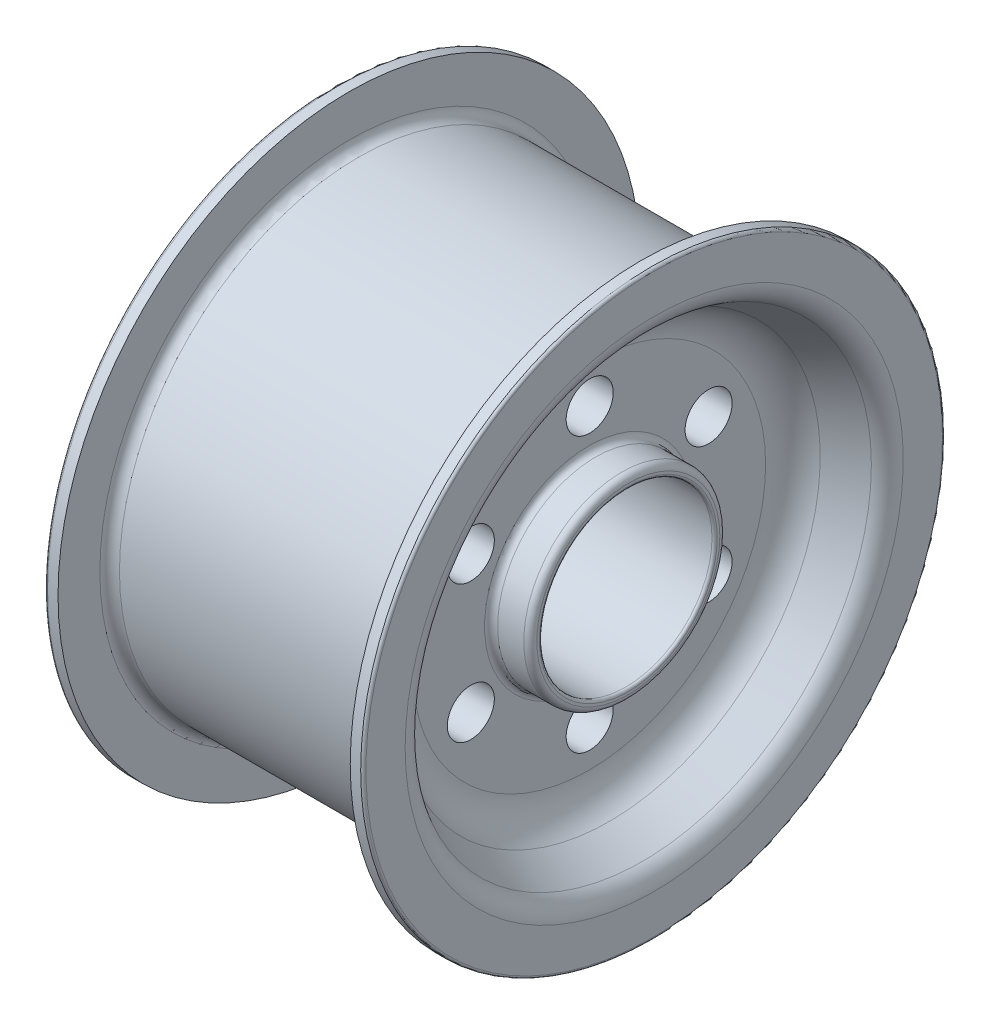
from build123d import *

# Parameters (mm, degrees)
SKETCH2_R          = 18
CUT_EXTRUDE1_DEPTH = 194.76
SKETCH3_R          = 66
CUT_EXTRUDE2_DEPTH = 224.76
FILLET1_R          = 5
FILLET2_R          = 2
FILLET3_R          = 5
FILLET4_R          = 2
SCALE1_SCALE       = 1.09591011


with BuildPart() as part:
    # Sketch1 → Revolve1 (revolve)
    with BuildSketch(Plane.XY):
        with BuildLine():
            ThreePointArc((87.505119212, 161.265917668), (76.165464745, 150.250468458), (72, 135))
            Line((72, 135), (72, 75))
            Line((72, 75), (102, 75))
            Line((102, 75), (102, 0))
            Line((102, 0), (-102, 0))
            Line((-102, 0), (-102, 75))
            Line((-102, 75), (-72, 75))
            Line((-72, 75), (-72, 135))
            ThreePointArc((-72, 135), (-76.165464745, 150.250468458), (-87.505119212, 161.265917668))
            Line((-87.505119212, 161.265917668), (-112.715347126, 175.178214694))
            ThreePointArc((-112.715347126, 175.178214694), (-119.330145565, 181.6038934), (-121.76, 190.5))
            Line((-121.76, 190.5), (-121.76, 222.5))
            Line((-121.76, 222.5), (-111.76, 222.5))
            Line((-111.76, 222.5), (-111.76, 190.5))
            ThreePointArc((-111.76, 190.5), (-109.563300859, 185.196699141), (-104.26, 183))
            Line((-104.26, 183), (104.26, 183))
            ThreePointArc((104.26, 183), (109.563300859, 185.196699141), (111.76, 190.5))
            Line((111.76, 190.5), (111.76, 222.5))
            Line((111.76, 222.5), (121.76, 222.5))
            Line((121.76, 222.5), (121.76, 190.5))
            ThreePointArc((121.76, 190.5), (119.330145565, 181.6038934), (112.715347126, 175.178214694))
            Line((112.715347126, 175.178214694), (87.505119212, 161.265917668))
        make_face()
    revolve(axis=Axis((0, 0, 0), (1, 0, 0)))

    # Sketch2 → Cut-Extrude1 (cut, through all)
    with BuildSketch(Plane(origin=(72, 0, 0), x_dir=(0, 0, -1), z_dir=(1, 0, 0))):
        with Locations((0.448204547, 106.008622634)):
            Circle(SKETCH2_R)
        with Locations((91.380871944, 53.508622634)):
            Circle(SKETCH2_R)
        with Locations((91.380871944, -51.491377366)):
            Circle(SKETCH2_R)
        with Locations((0.448204547, -103.991377366)):
            Circle(SKETCH2_R)
        with Locations((-90.48446285, -51.491377366)):
            Circle(SKETCH2_R)
        with Locations((-90.48446285, 53.508622634)):
            Circle(SKETCH2_R)
    extrude(amount=-CUT_EXTRUDE1_DEPTH, mode=Mode.SUBTRACT)

    # Sketch3 → Cut-Extrude2 (cut, through all)
    with BuildSketch(Plane(origin=(102, 0, 0), x_dir=(0, 0, -1), z_dir=(1, 0, 0))):
        Circle(SKETCH3_R)
    extrude(amount=-CUT_EXTRUDE2_DEPTH, mode=Mode.SUBTRACT)

    # Fillet1
    fillet1_edges = [part.edges().sort_by_distance(p)[0] for p in [
        (72, -75, 0),
        (102, -75, 0),
    ]]
    fillet(fillet1_edges, radius=FILLET1_R)

    # Fillet2
    fillet2_edges = [part.edges().sort_by_distance(p)[0] for p in [
        (-121.76, -222.5, 0),
        (121.76, -222.5, 0),
    ]]
    fillet(fillet2_edges, radius=FILLET2_R)

    # Fillet3
    fillet3_edges = [part.edges().sort_by_distance(p)[0] for p in [
        (-102, -75, 0),
        (-72, -75, 0),
    ]]
    fillet(fillet3_edges, radius=FILLET3_R)

    # Fillet4
    fillet4_edges = [part.edges().sort_by_distance(p)[0] for p in [
        (-102, 0, 66),
        (102, 0, 66),
    ]]
    fillet(fillet4_edges, radius=FILLET4_R)


with BuildPart() as part_1:
    # Scale1: scaled about (0, -0.057532792, 0.025566013)
    add(part.part.scale(SCALE1_SCALE).moved(Location((0, 0.005517976, -0.002452039))))


solid = part_1.part
